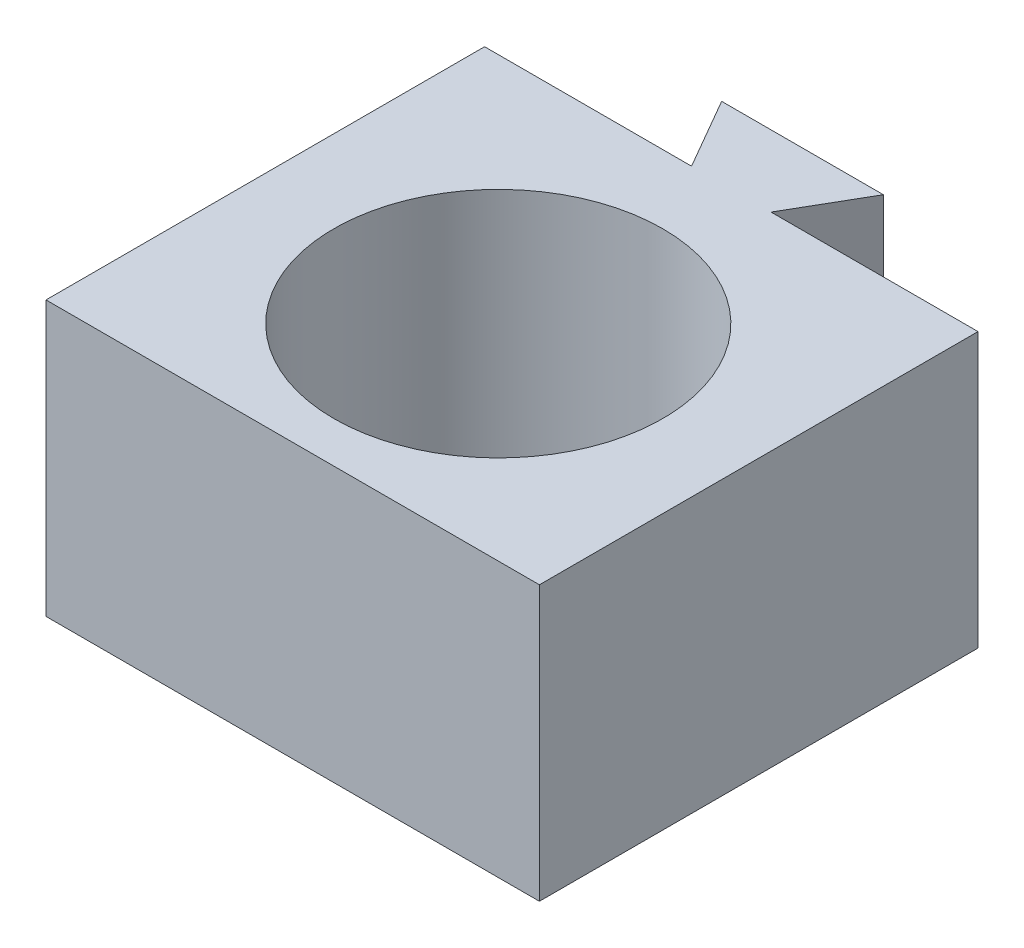
from build123d import *

# Parameters (mm, degrees)
SKETCH1_W           = 18
SKETCH1_H           = 10
BOSS_EXTRUDE1_DEPTH = 16
SKETCH6_R           = 6
CUT_EXTRUDE1_DEPTH  = 11
BOSS_EXTRUDE2_DEPTH = 8


with BuildPart() as part:
    # Sketch1 → Boss-Extrude1 (new body)
    with BuildSketch(Plane.XY):
        Rectangle(SKETCH1_W, SKETCH1_H)
    extrude(amount=BOSS_EXTRUDE1_DEPTH)

    # Sketch6 → Cut-Extrude1 (cut, through all)
    with BuildSketch(Plane(origin=(0, 5, 0), x_dir=(1, 0, 0), z_dir=(0, 1, 0))):
        with Locations((0, -8.5)):
            Circle(SKETCH6_R)
    extrude(amount=-CUT_EXTRUDE1_DEPTH, mode=Mode.SUBTRACT)

    # Sketch8 → Boss-Extrude2 (add)
    with BuildSketch(Plane(origin=(0, 5, 0), x_dir=(1, 0, 0), z_dir=(0, 1, 0))):
        Polygon((-1.45, 0), (-2.95, 2.598076211), (2.95, 2.598076211), (1.45, 0), align=None)
    extrude(amount=-BOSS_EXTRUDE2_DEPTH)


solid = part.part
